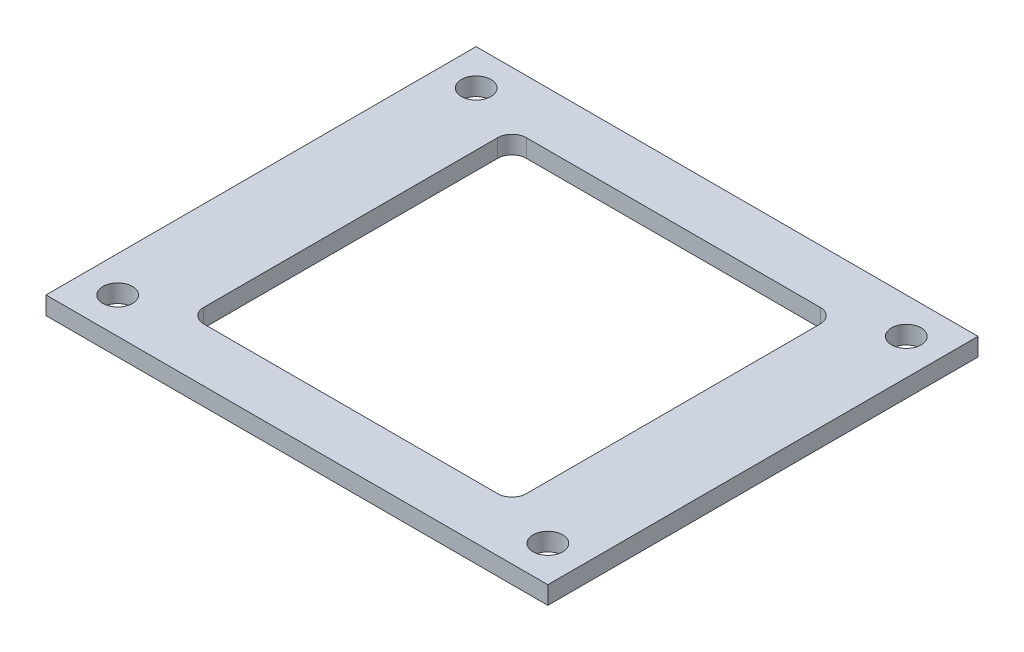
from build123d import *

# Parameters (mm, degrees)
SKETCH1_W           = 56
SKETCH1_H           = 48
SKETCH1_R           = 1.65
SKETCH1_W_2         = 36
SKETCH1_H_2         = 36
BOSS_EXTRUDE1_DEPTH = 2
FILLET1_R           = 1.6


with BuildPart() as part:
    # Sketch1 → Boss-Extrude1 (new body)
    with BuildSketch(Plane(origin=(0, 0, 0), x_dir=(1, 0, 0), z_dir=(0, 1, 0))):
        Rectangle(SKETCH1_W, SKETCH1_H)
        with Locations((-24, 20)):
            Circle(SKETCH1_R, mode=Mode.SUBTRACT)
        with Locations((-24, -20)):
            Circle(SKETCH1_R, mode=Mode.SUBTRACT)
        with Locations((24, 20)):
            Circle(SKETCH1_R, mode=Mode.SUBTRACT)
        with Locations((24, -20)):
            Circle(SKETCH1_R, mode=Mode.SUBTRACT)
        Rectangle(SKETCH1_W_2, SKETCH1_H_2, mode=Mode.SUBTRACT)
    extrude(amount=BOSS_EXTRUDE1_DEPTH)

    # Fillet1
    fillet1_edges = [part.edges().sort_by_distance(p)[0] for p in [
        (18, 1, -18),
        (-18, 1, -18),
        (-18, 1, 18),
        (18, 1, 18),
    ]]
    fillet(fillet1_edges, radius=FILLET1_R)


solid = part.part
